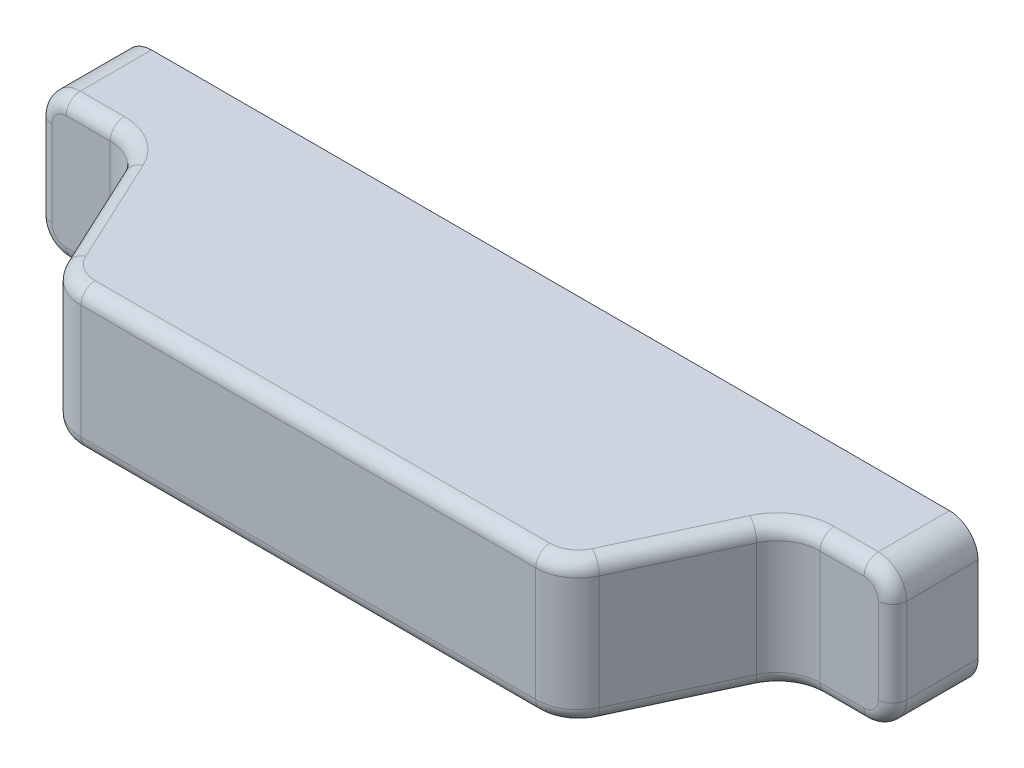
from build123d import *

# Parameters (mm, degrees)
SKETCH1_W           = 60
SKETCH1_H           = 10
BOSS_EXTRUDE1_DEPTH = 17
CUT_EXTRUDE1_REACH  = 12
FILLET1_R           = 3
FILLET2_R           = 2
FILLET3_R           = 1


with BuildPart() as part:
    # Sketch1 → Boss-Extrude1 (new body)
    with BuildSketch(Plane.XY):
        with Locations((-89, -92.757283518)):
            Rectangle(SKETCH1_W, SKETCH1_H)
    extrude(amount=BOSS_EXTRUDE1_DEPTH)

    # Sketch2 → Cut-Extrude1 (cut, up to next)
    with BuildSketch(Plane.XZ.offset(97.757283518), mode=Mode.PRIVATE) as cut_extrude1_sk1:
        Polygon((-106.87061576, 17), (-112, 6), (-119, 6), (-119, 17), align=None)
    cut_extrude1_tool1 = extrude(cut_extrude1_sk1.sketch, amount=-CUT_EXTRUDE1_REACH, mode=Mode.PRIVATE) & part.part
    add(cut_extrude1_tool1.solids().sort_by_distance((-114.103037, -97.757284, 11.991593))[0], mode=Mode.SUBTRACT)
    # Sketch2 → Cut-Extrude1 (cut, up to next)
    with BuildSketch(Plane.XZ.offset(97.757283518), mode=Mode.PRIVATE) as cut_extrude1_sk2:
        Polygon((-59, 17), (-71.12938424, 17), (-66, 6), (-59, 6), align=None)
    cut_extrude1_tool2 = extrude(cut_extrude1_sk2.sketch, amount=-CUT_EXTRUDE1_REACH, mode=Mode.PRIVATE) & part.part
    add(cut_extrude1_tool2.solids().sort_by_distance((-63.896963, -97.757284, 11.991593))[0], mode=Mode.SUBTRACT)

    # Fillet1
    fillet1_edges = [part.edges().sort_by_distance(p)[0] for p in [
        (-66, -92.757283518, 6),
        (-71.12938424, -92.757283518, 17),
        (-106.87061576, -92.757283518, 17),
        (-112, -92.757283518, 6),
    ]]
    fillet(fillet1_edges, radius=FILLET1_R)

    # Fillet2
    fillet2_edges = [part.edges().sort_by_distance(p)[0] for p in [
        (-59, -97.757283518, 3),
        (-119, -97.757283518, 3),
        (-59, -87.757283518, 3),
        (-119, -87.757283518, 3),
    ]]
    fillet(fillet2_edges, radius=FILLET2_R)

    # Fillet3
    fillet3_edges = [part.edges().sort_by_distance(p)[0] for p in [
        (-62.544394609, -97.757283518, 6),
        (-65.700688043, -97.757283518, 6.469825663),
        (-68.56469212, -97.757283518, 11.5),
        (-71.428696197, -97.757283518, 16.530174337),
        (-115.455605391, -97.757283518, 6),
        (-89, -97.757283518, 17),
        (-112.299311957, -97.757283518, 6.469825663),
        (-106.571303803, -97.757283518, 16.530174337),
        (-109.43530788, -97.757283518, 11.5),
        (-59.585786438, -97.171497081, 6),
        (-59, -92.757283518, 6),
        (-62.544394609, -87.757283518, 6),
        (-59.585786438, -88.343069955, 6),
        (-65.700688043, -87.757283518, 6.469825663),
        (-68.56469212, -87.757283518, 11.5),
        (-118.414213562, -97.171497081, 6),
        (-71.428696197, -87.757283518, 16.530174337),
        (-119, -92.757283518, 6),
        (-115.455605391, -87.757283518, 6),
        (-118.414213562, -88.343069955, 6),
        (-89, -87.757283518, 17),
        (-112.299311957, -87.757283518, 6.469825663),
        (-106.571303803, -87.757283518, 16.530174337),
        (-109.43530788, -87.757283518, 11.5),
    ]]
    fillet(fillet3_edges, radius=FILLET3_R)


solid = part.part
